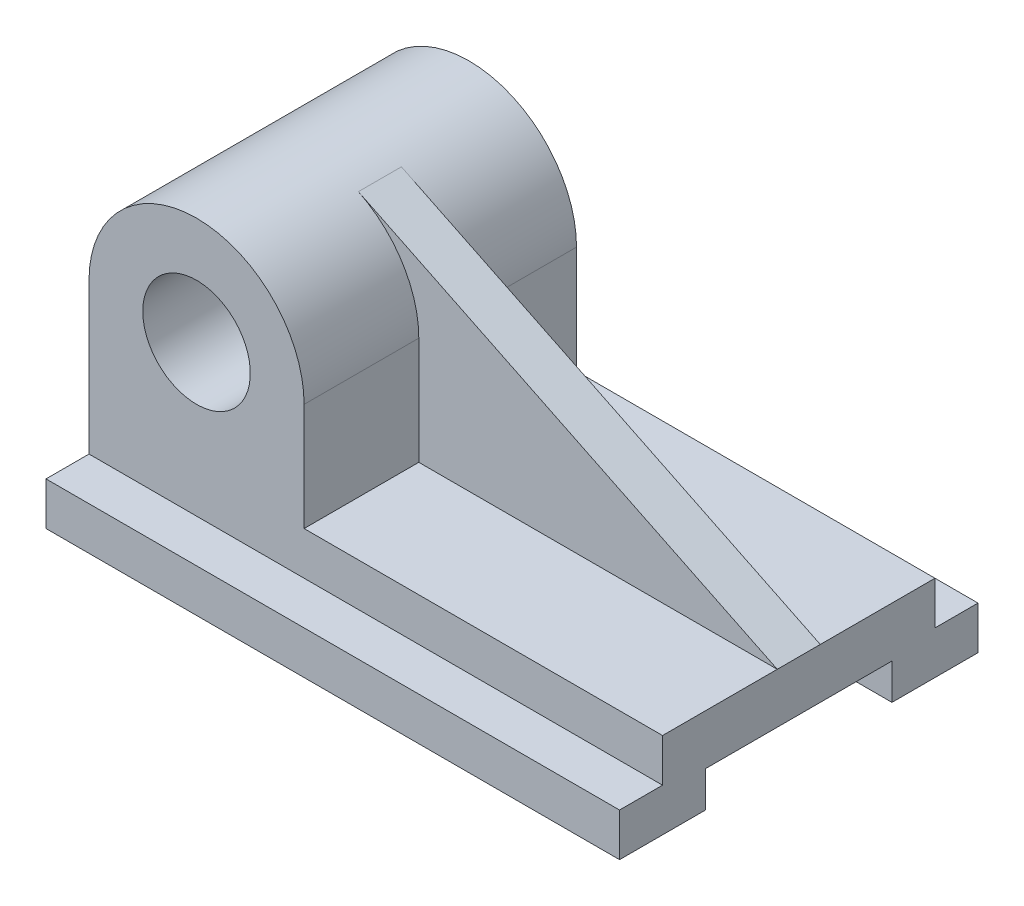
from build123d import *

# Parameters (mm, degrees)
BOSS_EXTRUDE1_DEPTH = 160
SKETCH2_R           = 15
BOSS_EXTRUDE4_DEPTH = 76
RIB4_REACH          = 187.313
SKETCH5_WALL_W      = 502.626496624
SKETCH5_WALL_H      = 12


with BuildPart() as part:
    # Sketch1 → Boss-Extrude1 (new body)
    with BuildSketch(Plane(origin=(0, 0, 0), x_dir=(0, 0, -1), z_dir=(1, 0, 0))):
        Polygon((-26, 5), (26, 5), (26, -5), (50, -5), (50, 7), (38, 7), (38, 19), (-38, 19), (-38, 7), (-50, 7), (-50, -5), (-26, -5), align=None)
    extrude(amount=-BOSS_EXTRUDE1_DEPTH)

    # Sketch2 → Boss-Extrude4 (add)
    with BuildSketch(Plane(origin=(0, 0, -38), x_dir=(-1, 0, 0), z_dir=(0, 0, -1))):
        with BuildLine():
            Line((160, 19), (160, 49))
            ThreePointArc((160, 49), (130, 79), (100, 49))
            Line((100, 49), (100, 19))
            Line((100, 19), (160, 19))
        make_face()
        with Locations((130, 49)):
            Circle(SKETCH2_R, mode=Mode.SUBTRACT)
    extrude(amount=-BOSS_EXTRUDE4_DEPTH)

    # Sketch5 wall → Rib4 (add, up to next)
    with BuildSketch(Plane(origin=(-58.426966292, 47.483146068, 0), x_dir=(-0.898876404493, 0.438202247193, 0), z_dir=(-0.438202247193, -0.898876404493, 0)), mode=Mode.PRIVATE) as rib4_sk1:
        Rectangle(SKETCH5_WALL_W, SKETCH5_WALL_H)
    rib4_tool1 = extrude(rib4_sk1.sketch, amount=RIB4_REACH, mode=Mode.PRIVATE) - part.part
    add(rib4_tool1.solids().sort_by_distance((-58.426966292, 47.483146068, 0))[0])


solid = part.part
